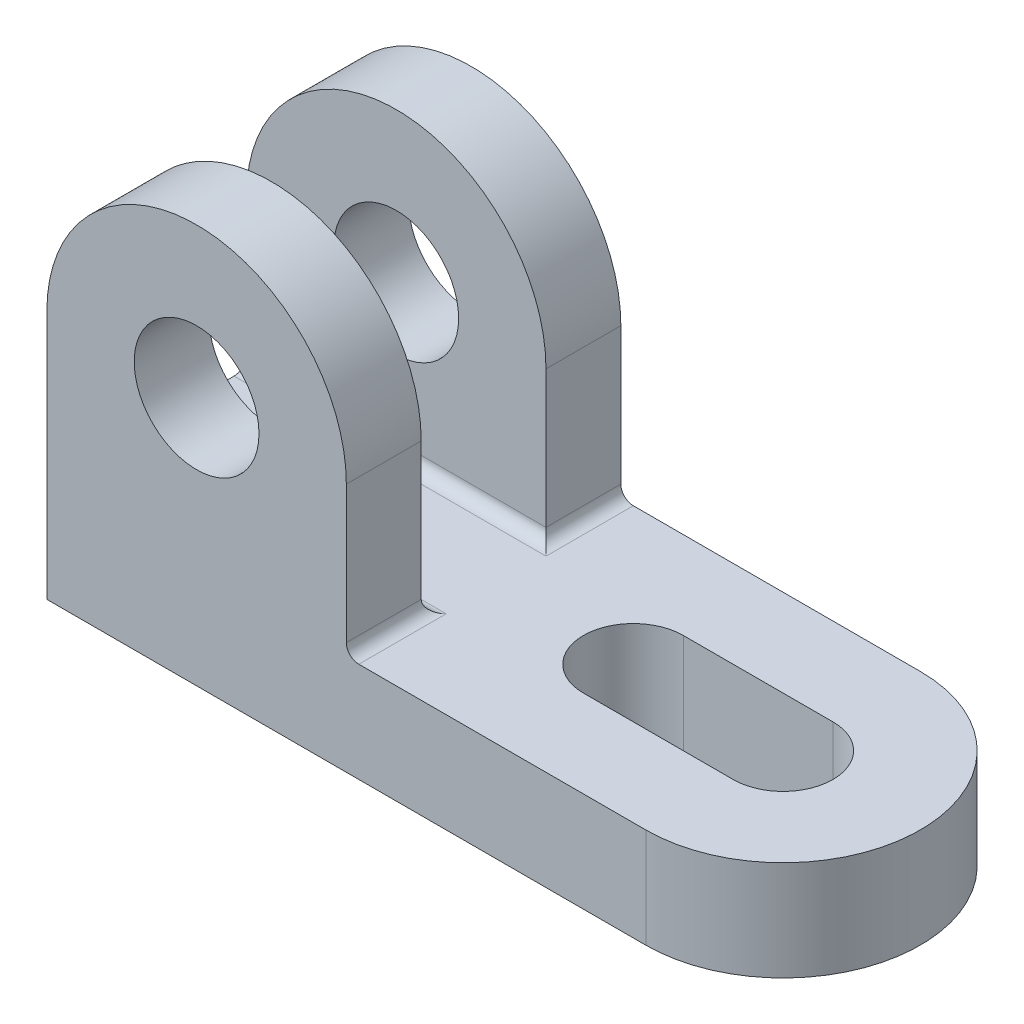
from build123d import *

# Parameters (mm, degrees)
SKETCH1_R           = 22
BOSS_EXTRUDE1_DEPTH = 16
CUT_EXTRUDE1_DEPTH  = 16
SKETCH3_R           = 10
BOSS_EXTRUDE2_DEPTH = 12
FILLET1_R           = 2


with BuildPart() as part:
    # Sketch1 → Boss-Extrude1 (new body)
    with BuildSketch(Plane(origin=(0, 0, 0), x_dir=(1, 0, 0), z_dir=(0, 1, 0))):
        with BuildLine():
            Line((37, 22), (-59, 22))
            Line((-59, 22), (-59, -22))
            Line((-59, -22), (37, -22))
            ThreePointArc((37, -22), (15, 0), (37, 22))
        make_face()
        with Locations((37, 0)):
            Circle(SKETCH1_R)
    extrude(amount=BOSS_EXTRUDE1_DEPTH)

    # Sketch2 → Cut-Extrude1 (cut)
    with BuildSketch(Plane(origin=(0, 16, 0), x_dir=(1, 0, 0), z_dir=(0, 1, 0))):
        with BuildLine():
            Line((37, -8), (13, -8))
            ThreePointArc((13, -8), (5, 0), (13, 8))
            Line((13, 8), (37, 8))
            ThreePointArc((37, 8), (45, 0), (37, -8))
        make_face()
    extrude(amount=-CUT_EXTRUDE1_DEPTH, mode=Mode.SUBTRACT)

    # Sketch3 → Boss-Extrude2 (add)
    with BuildSketch(Plane.XY.offset(22)):
        with BuildLine():
            Line((-59, 40), (-59, 16))
            Line((-59, 16), (-11, 16))
            Line((-11, 16), (-11, 40))
            ThreePointArc((-11, 40), (-35, 64), (-59, 40))
        make_face()
        with Locations((-35, 40)):
            Circle(SKETCH3_R, mode=Mode.SUBTRACT)
    boss_extrude2 = extrude(amount=-BOSS_EXTRUDE2_DEPTH)

    # Mirror1: Boss-Extrude2 across plane
    add(boss_extrude2.mirror(Plane.XY))

    # Fillet1
    fillet1_edges = [part.edges().sort_by_distance(p)[0] for p in [
        (-11, 16, 16),
        (-35, 16, 10),
        (-11, 16, -16),
        (-35, 16, -10),
    ]]
    fillet(fillet1_edges, radius=FILLET1_R)


solid = part.part
